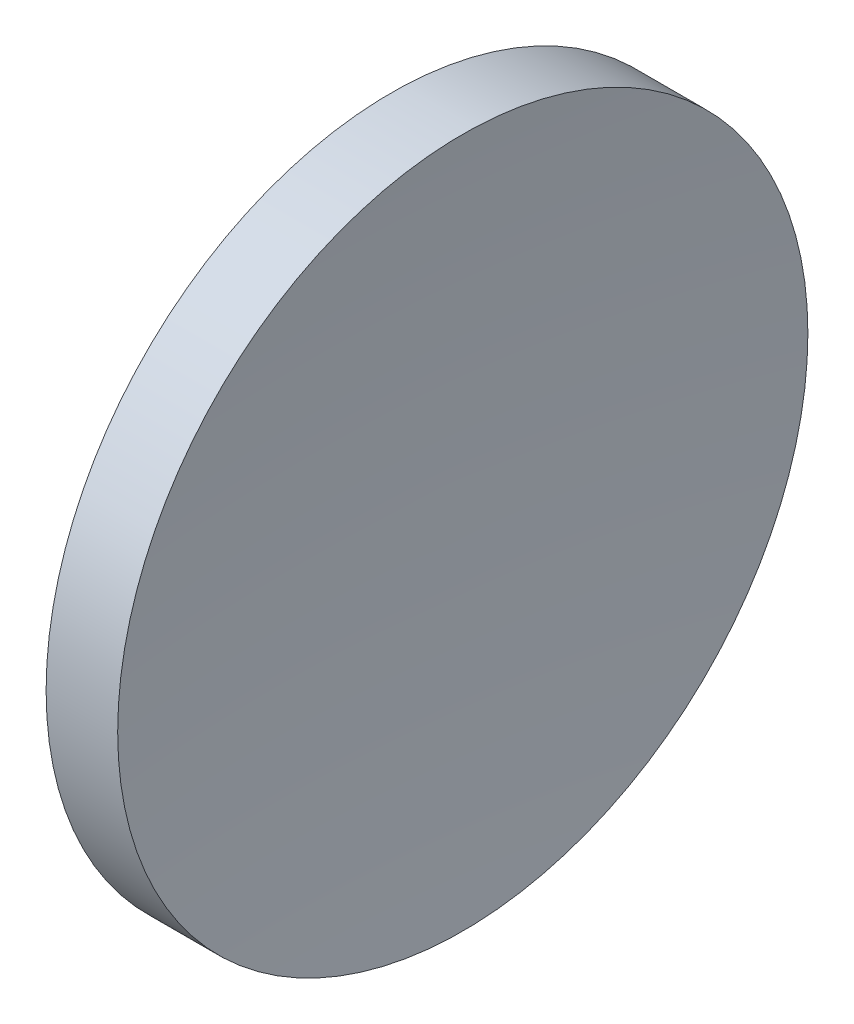
from build123d import *


with BuildPart() as part:
    # 草图1 → 旋转1 (revolve)
    with BuildSketch(Plane.XY, mode=Mode.PRIVATE) as revolve_1_sk:
        with BuildLine():
            Line((57.532337053, 32.610768129), (57.532337053, 45.110768129))
            Line((57.532337053, 45.110768129), (60.124582369, 45.110768129))
            ThreePointArc((60.124582369, 45.110768129), (59.676948439, 38.867946677), (59.532337053, 32.610768129))
            Line((59.532337053, 32.610768129), (57.532337053, 32.610768129))
        make_face()
    revolve(revolve_1_sk.sketch.rotate(Axis((56.10091508, 32.610768129, 0), (1, 0, 0)), 90), axis=Axis((56.10091508, 32.610768129, 0), (1, 0, 0)))  # turned: the seam where the file's is


solid = part.part
